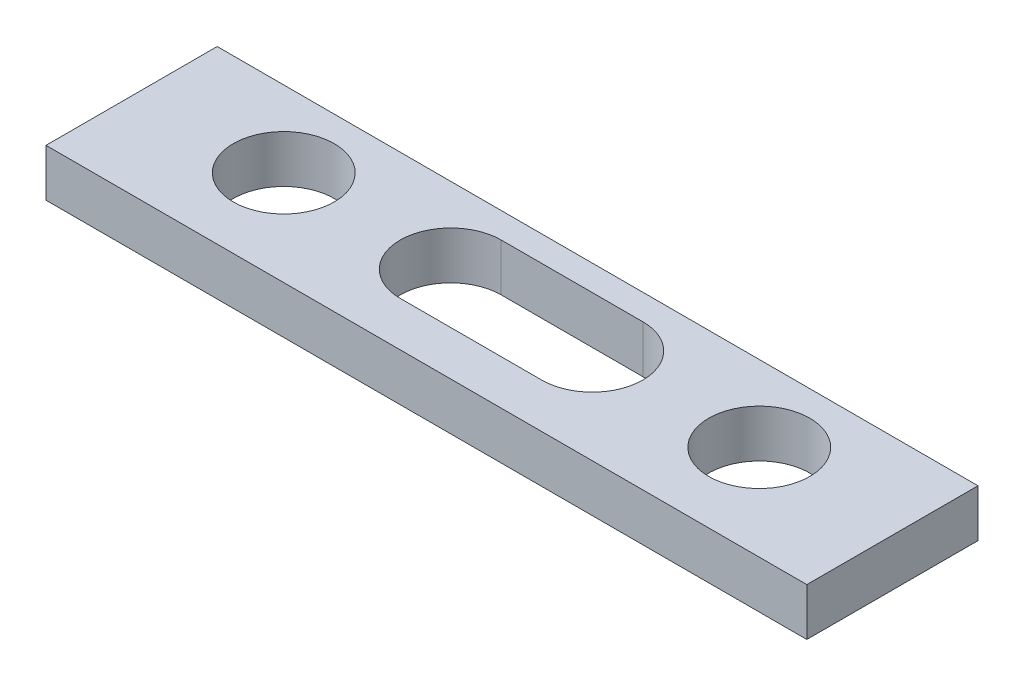
from build123d import *

# Parameters (mm, degrees)
SKETCH1_W               = 22.86
SKETCH1_H               = 6.35
EXTRUDE1_DEPTH          = 50.8
EXTRUDE1_DEPTH_BACK     = 50.8
F_1_2_CLEARANCE_HOLE1_D = 13.49248
CUT_EXTRUDE1_DEPTH      = 7.35


with BuildPart() as part:
    # Sketch1 → Extrude1 (new body, two sides)
    with BuildSketch(Plane(origin=(0, 0, 0), x_dir=(0, 0, -1), z_dir=(1, 0, 0))) as extrude1_sk:
        Rectangle(SKETCH1_W, SKETCH1_H)
    extrude(amount=EXTRUDE1_DEPTH)
    extrude(extrude1_sk.sketch, amount=-EXTRUDE1_DEPTH_BACK)

    # 1_2 Clearance Hole1 (through all)
    with Locations(Plane(origin=(0, 3.175, 0), x_dir=(-1, 0, 0), z_dir=(0, 1, 0))):
        with Locations((31.75, -1.27), (-31.75, -1.27)):
            Hole(F_1_2_CLEARANCE_HOLE1_D / 2)

    # Sketch6 → Cut-Extrude1 (cut, through all)
    with BuildSketch(Plane(origin=(0, 3.175, 0), x_dir=(-1, 0, 0), z_dir=(0, 1, 0))):
        with BuildLine():
            Line((-9.452589884, -8.016875), (9.452589807, -8.016875))
            ThreePointArc((9.452589807, -8.016875), (16.199464807, -1.27), (9.452589807, 5.476875))
            Line((9.452589807, 5.476875), (-9.452589884, 5.476875))
            ThreePointArc((-9.452589884, 5.476875), (-16.199464884, -1.27), (-9.452589884, -8.016875))
        make_face()
    extrude(amount=-CUT_EXTRUDE1_DEPTH, mode=Mode.SUBTRACT)


solid = part.part
